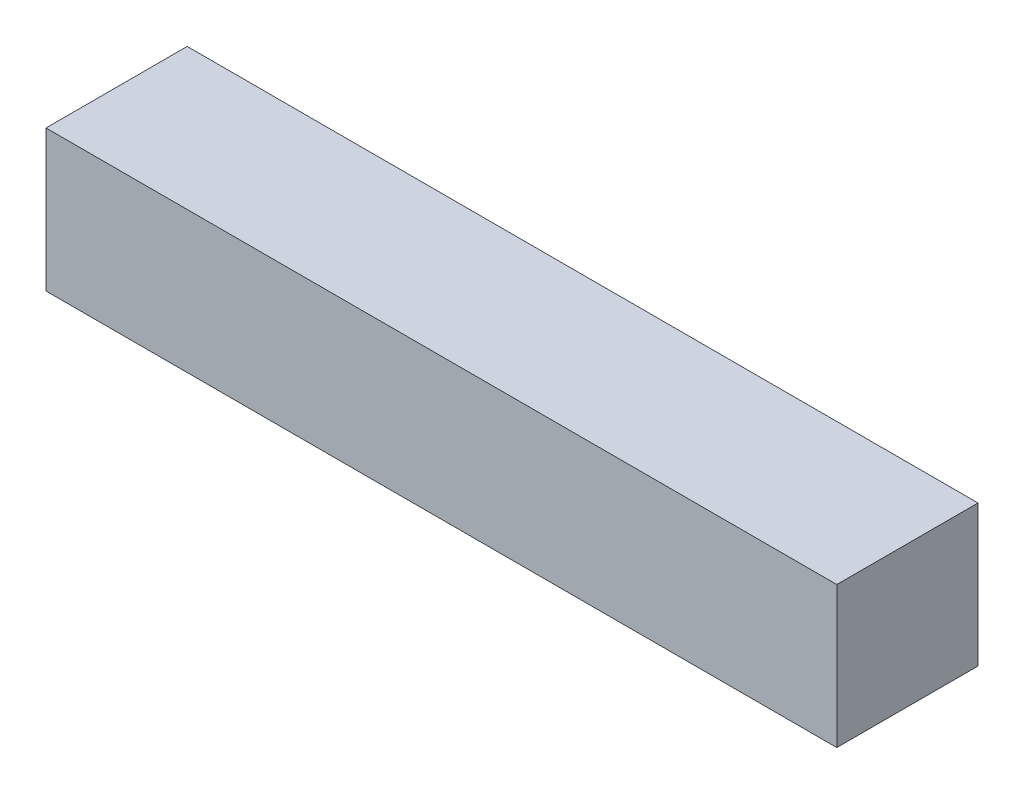
from build123d import *

# Parameters (mm, degrees)
SKETCH1_W           = 140
SKETCH1_H           = 25
BOSS_EXTRUDE1_DEPTH = 25


with BuildPart() as part:
    # Sketch1 → Boss-Extrude1 (new body)
    with BuildSketch(Plane(origin=(0, 0, 0), x_dir=(1, 0, 0), z_dir=(0, 1, 0))):
        Rectangle(SKETCH1_W, SKETCH1_H)
    extrude(amount=BOSS_EXTRUDE1_DEPTH)


solid = part.part
